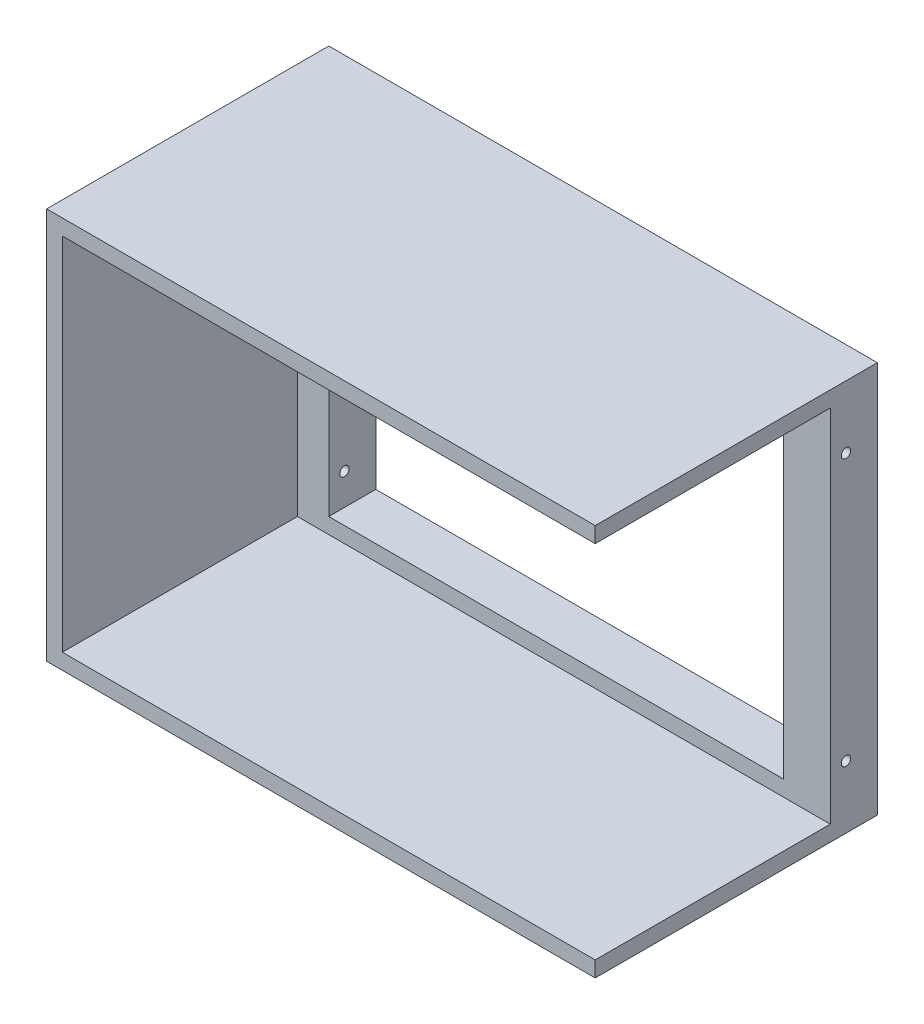
from build123d import *

# Parameters (mm, degrees)
SKETCH_1_W          = 350
SKETCH_1_H          = 250
EXTRUDE_1_DEPTH     = 30
SKETCH_2_W          = 290
SKETCH_2_H          = 210
CUT_EXTRUDE_1_DEPTH = 30
SKETCH_3_R          = 3
CUT_EXTRUDE_2_DEPTH = 351
SKETCH_4_W          = 350
SKETCH_4_H          = 250
SKETCH_4_W_2        = 330
SKETCH_4_H_2        = 230
EXTRUDE_2_DEPTH     = 150
SKETCH_5_W          = 10
SKETCH_5_H          = 230
CUT_EXTRUDE_3_DEPTH = 150


with BuildPart() as part:
    # 草图1 → 凸台-拉伸1 (new body)
    with BuildSketch(Plane.XY):
        Rectangle(SKETCH_1_W, SKETCH_1_H)
    extrude(amount=EXTRUDE_1_DEPTH)

    # 草图2 → 切除-拉伸1 (cut)
    with BuildSketch(Plane.XY.offset(30)):
        Rectangle(SKETCH_2_W, SKETCH_2_H)
    extrude(amount=-CUT_EXTRUDE_1_DEPTH, mode=Mode.SUBTRACT)

    # 草图3 → 切除-拉伸2 (cut, through all)
    with BuildSketch(Plane(origin=(175, 0, 0), x_dir=(0, 0, -1), z_dir=(1, 0, 0))):
        with Locations((-20, 85)):
            Circle(SKETCH_3_R)
    cut_extrude_2 = extrude(amount=-CUT_EXTRUDE_2_DEPTH, mode=Mode.SUBTRACT)

    # 镜向1: 切除-拉伸2 across plane
    add(cut_extrude_2.mirror(Plane.ZX), mode=Mode.SUBTRACT)

    # 草图4 → 凸台-拉伸2 (add)
    with BuildSketch(Plane.XY.offset(30)):
        Rectangle(SKETCH_4_W, SKETCH_4_H)
        Rectangle(SKETCH_4_W_2, SKETCH_4_H_2, mode=Mode.SUBTRACT)
    extrude(amount=EXTRUDE_2_DEPTH)

    # 草图5 → 切除-拉伸3 (cut)
    with BuildSketch(Plane.XY.offset(180)):
        with Locations((170, 0)):
            Rectangle(SKETCH_5_W, SKETCH_5_H)
    extrude(amount=-CUT_EXTRUDE_3_DEPTH, mode=Mode.SUBTRACT)


solid = part.part
